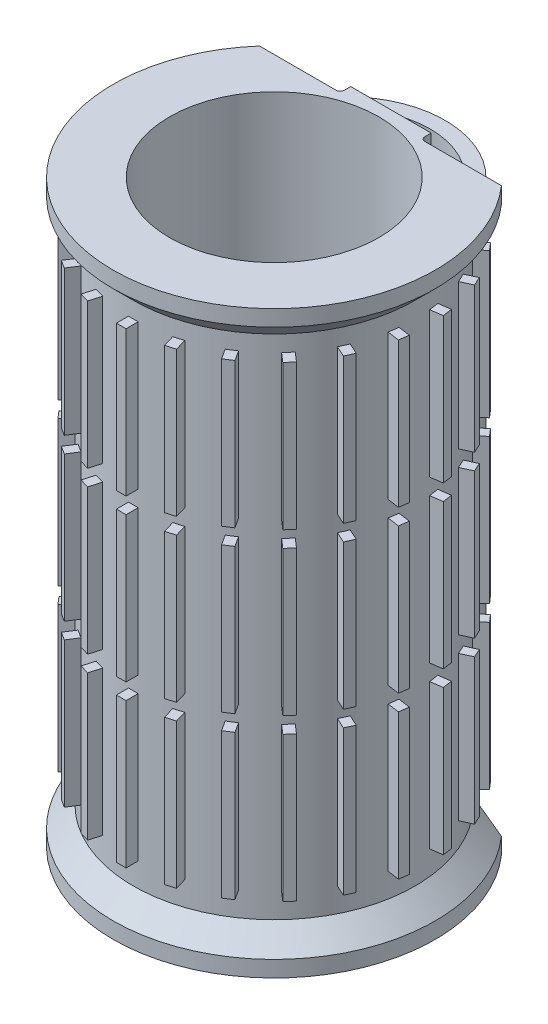
from build123d import *

# Parameters (mm, degrees)
SKETCH_2_W               = 1.2
SKETCH_2_H               = 18
EXTRUDE_1_DEPTH          = 1.510289
PATTERN_CIRCULAR_1_COUNT = 22
CUT_EXTRUDE_1_DEPTH      = 73
SKETCH_4_W               = 10
SKETCH_4_H               = 1.3
EXTRUDE_2_DEPTH          = 72
SKETCH_5_W               = 2
SKETCH_5_H               = 63
FILLET_1_R               = 0.5


with BuildPart() as part:
    # 草图1 → 旋转1 (revolve)
    with BuildSketch(Plane.XY):
        Polygon((13, 72), (13, 0), (20, 0), (20, 2), (17.5, 4.5), (17.5, 67.5), (20, 70), (20, 72), align=None)
    revolve(axis=Axis((0, 0, 0), (0, 1, 0)))

    # 草图2 → 凸台-拉伸1 (add)
    with BuildSketch(Plane.XY.offset(19)):
        with Locations((0, 36.5)):
            Rectangle(SKETCH_2_W, SKETCH_2_H)
        with Locations((0, 56.5)):
            Rectangle(SKETCH_2_W, SKETCH_2_H)
        with Locations((0, 16.5)):
            Rectangle(SKETCH_2_W, SKETCH_2_H)
    extrude_1 = extrude(amount=-EXTRUDE_1_DEPTH)

    # 阵列(圆周)1: 凸台-拉伸1 ×22 about axis
    pattern_circular_1_axis = Axis((0, 0, 0), (0, 1, 0))
    for i in range(1, PATTERN_CIRCULAR_1_COUNT):
        add(extrude_1.rotate(pattern_circular_1_axis, i * 360 / PATTERN_CIRCULAR_1_COUNT))

    # 草图3 → 切除-拉伸1 (cut, through all)
    with BuildSketch(Plane(origin=(0, 72, 0), x_dir=(1, 0, 0), z_dir=(0, 1, 0))):
        with BuildLine():
            ThreePointArc((15.025311977, 13.2), (0, 20), (-15.025311977, 13.2))
            Line((-15.025311977, 13.2), (15.025311977, 13.2))
        make_face()
    extrude(amount=-CUT_EXTRUDE_1_DEPTH, mode=Mode.SUBTRACT)

    # 草图4 → 凸台-拉伸2 (add)
    with BuildSketch(Plane(origin=(0, 72, 0), x_dir=(1, 0, 0), z_dir=(0, 1, 0))):
        with Locations((0, 13.85)):
            Rectangle(SKETCH_4_W, SKETCH_4_H)
    extrude(amount=-EXTRUDE_2_DEPTH)

    # 扫描1: sweep along a path in 草图7
    with BuildLine(Plane(origin=(0, 30, 0), x_dir=(-1, 0, 0), z_dir=(0, -1, 0))) as sweep_1_path:
        ThreePointArc((10.489560479, 13.2), (-1.506377689, 20.198290285), (-11.2265579, 10.278779403))
    # 草图5 → 扫描1 (sweep)
    with BuildSketch(Plane(origin=(0, 0, -13.2), x_dir=(-1, 0, 0), z_dir=(0, 0, -1))):
        with Locations((10.489560479, 36)):
            Rectangle(SKETCH_5_W, SKETCH_5_H)
    sweep(path=sweep_1_path.line)

    # 圆角1
    fillet_1_edges = [part.edges().sort_by_distance(p)[0] for p in [
        (-5, 36, -13.2),
        (5, 36, -13.2),
    ]]
    fillet(fillet_1_edges, radius=FILLET_1_R)


solid = part.part
